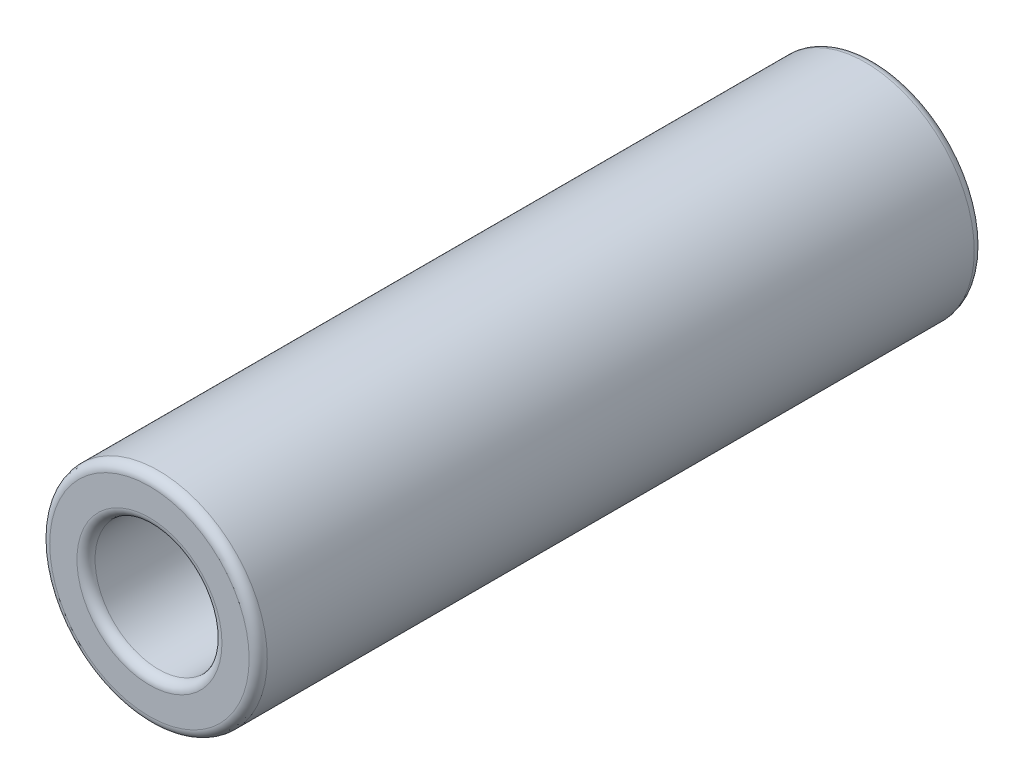
from build123d import *

# Parameters (mm, degrees)
SZKIC1_R                    = 6
SZKIC1_R_2                  = 3.5
DODANIE_WYCI_GNI_CIE1_DEPTH = 40
ZAOKR_GLENIE2_R             = 0.5


with BuildPart() as part:
    # Szkic1 → Dodanie-wyciągnięcie1 (new body)
    with BuildSketch(Plane.XY):
        Circle(SZKIC1_R)
        Circle(SZKIC1_R_2, mode=Mode.SUBTRACT)
    extrude(amount=DODANIE_WYCI_GNI_CIE1_DEPTH)

    # Zaokrąglenie2
    zaokr_glenie2_edges = [part.edges().sort_by_distance(p)[0] for p in [
        (-6, 0, 0),
        (-6, 0, 40),
        (-3.5, 0, 0),
        (-3.5, 0, 40),
    ]]
    fillet(zaokr_glenie2_edges, radius=ZAOKR_GLENIE2_R)


solid = part.part
